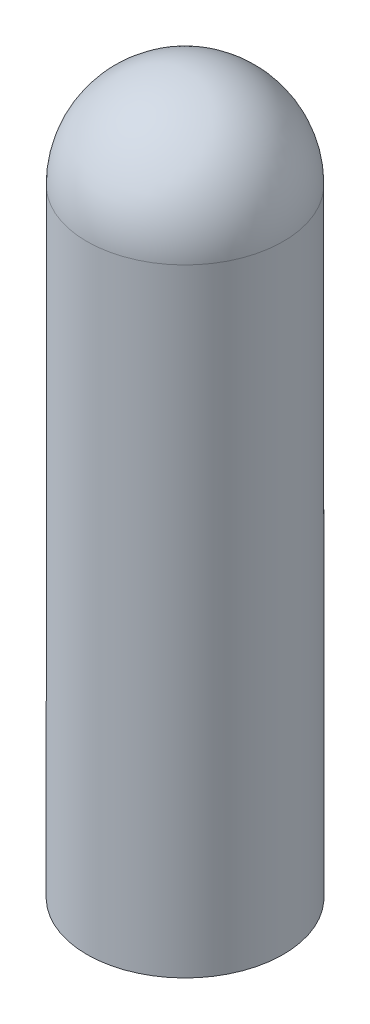
from build123d import *

# Parameters (mm, degrees)
SKETCH2_R          = 3.9751
CUT_EXTRUDE1_DEPTH = 27.7749


with BuildPart() as part:
    # Sketch1 → Revolve1 (revolve)
    with BuildSketch(Plane.XY):
        with BuildLine():
            Line((-4.3561, 0), (-4.3561, 27.3939))
            ThreePointArc((-4.3561, 27.3939), (-3.08022785, 30.47412785), (0, 31.75))
            Line((0, 31.75), (0, 0))
            Line((0, 0), (-4.3561, 0))
        make_face()
    revolve(axis=Axis((0, 0, 0), (0, -1, 0)))

    # Sketch2 → Cut-Extrude1 (cut)
    with BuildSketch(Plane.XZ):
        Circle(SKETCH2_R)
    extrude(amount=-CUT_EXTRUDE1_DEPTH, mode=Mode.SUBTRACT)


solid = part.part
